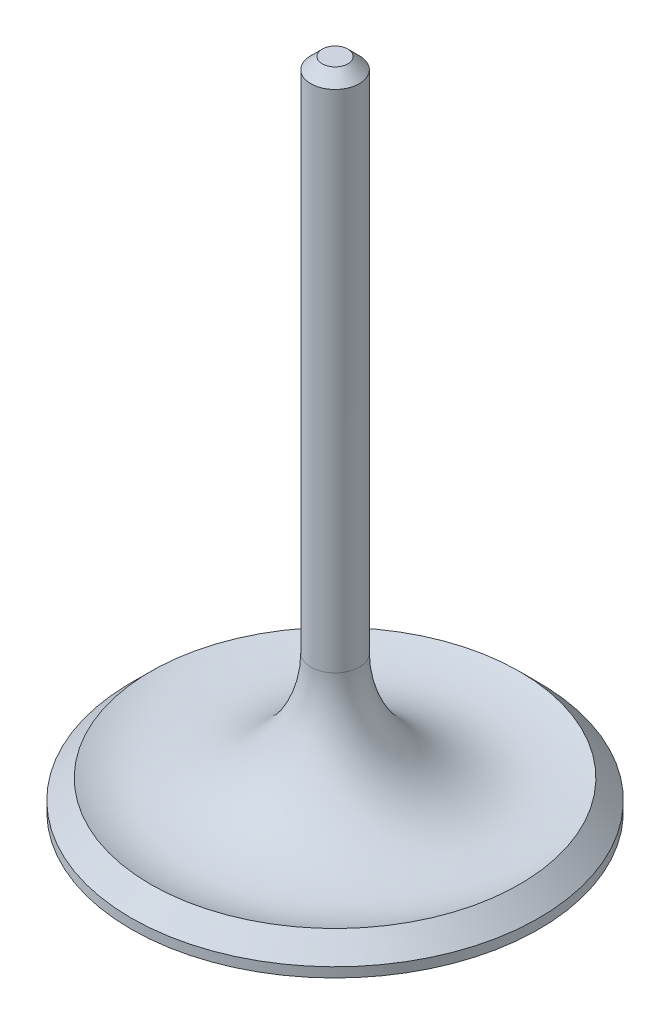
from build123d import *

# Parameters (mm, degrees)
CHAMFER1_SIZE = 1.5


with BuildPart() as part:
    # Sketch2 → Revolve1 (revolve)
    with BuildSketch(Plane.XY):
        with BuildLine():
            Line((0, 0), (26.67, 0))
            Line((26.67, 0), (26.67, 1.27))
            Line((26.67, 1.27), (24.13, 3.81))
            ThreePointArc((24.13, 3.81), (9.893843865, 5.312197185), (3.175, 17.952682737))
            Line((3.175, 17.952682737), (3.175, 85.55))
            Line((3.175, 85.55), (0, 85.55))
            Line((0, 85.55), (0, 0))
        make_face()
    revolve(axis=Axis((0, 85.55, 0), (0, -1, 0)))

    # Chamfer1
    chamfer1_edges = [part.edges().sort_by_distance(p)[0] for p in [
        (-3.175, 85.55, 0),
    ]]
    chamfer(chamfer1_edges, length=CHAMFER1_SIZE)


solid = part.part
